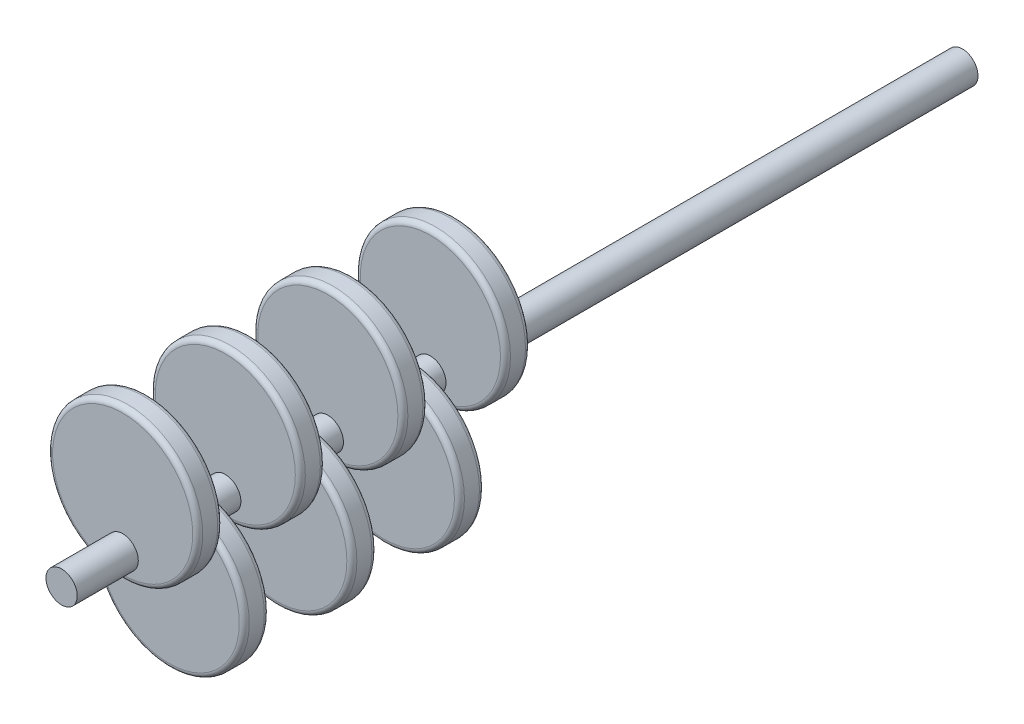
from build123d import *

# Parameters (mm, degrees)
SKETCH_1_R             = 3.125
EXTRUDE_1_DEPTH        = 90
EXTRUDE_START          = -12.2
SKETCH_2_R             = 15
EXTRUDE_2_DEPTH        = 5
PATTERN_LINEAR_1_COUNT = 4
PATTERN_LINEAR_1_PITCH = 20.5
EXTRUDE_START_2        = -21.5
SKETCH_3_R             = 15
EXTRUDE_3_DEPTH        = 5
PATTERN_LINEAR_2_COUNT = 3
PATTERN_LINEAR_2_PITCH = 21.5
FILLET_1_R             = 1


with BuildPart() as part:
    # 草图1 → 凸台-拉伸1 (new body, symmetric)
    with BuildSketch(Plane.XY):
        Circle(SKETCH_1_R)
    extrude(amount=EXTRUDE_1_DEPTH, both=True)

    # 草图2 → 凸台-拉伸2 (add)
    with BuildSketch(Plane.XY.offset(90).offset(EXTRUDE_START)):
        with Locations((0, 10)):
            Circle(SKETCH_2_R)
    extrude_2 = extrude(amount=-EXTRUDE_2_DEPTH)

    # 阵列(线性)1: 凸台-拉伸2 ×4
    with Locations(*[(0, 0, -i * PATTERN_LINEAR_1_PITCH) for i in range(1, PATTERN_LINEAR_1_COUNT)]):
        add(extrude_2)

    # 草图3 → 凸台-拉伸3 (add)
    with BuildSketch(Plane.XY.offset(90).offset(EXTRUDE_START_2)):
        with Locations((0, -10)):
            Circle(SKETCH_3_R)
    extrude_3 = extrude(amount=-EXTRUDE_3_DEPTH)

    # 阵列(线性)2: 凸台-拉伸3 ×3
    with Locations(*[(0, 0, -i * PATTERN_LINEAR_2_PITCH) for i in range(1, PATTERN_LINEAR_2_COUNT)]):
        add(extrude_3)

    # 圆角1
    fillet_1_edges = [part.edges().sort_by_distance(p)[0] for p in [
        (-15, 10, 52.3),
        (-15, 10, 57.3),
        (-15, 10, 31.8),
        (-15, 10, 36.8),
        (-15, 10, 11.3),
        (-15, 10, 16.3),
        (-15, -10, 63.5),
        (-15, -10, 68.5),
        (-15, -10, 42),
        (-15, -10, 47),
        (-15, -10, 20.5),
        (-15, -10, 25.5),
        (-15, 10, 72.8),
        (-15, 10, 77.8),
    ]]
    fillet(fillet_1_edges, radius=FILLET_1_R)


solid = part.part
